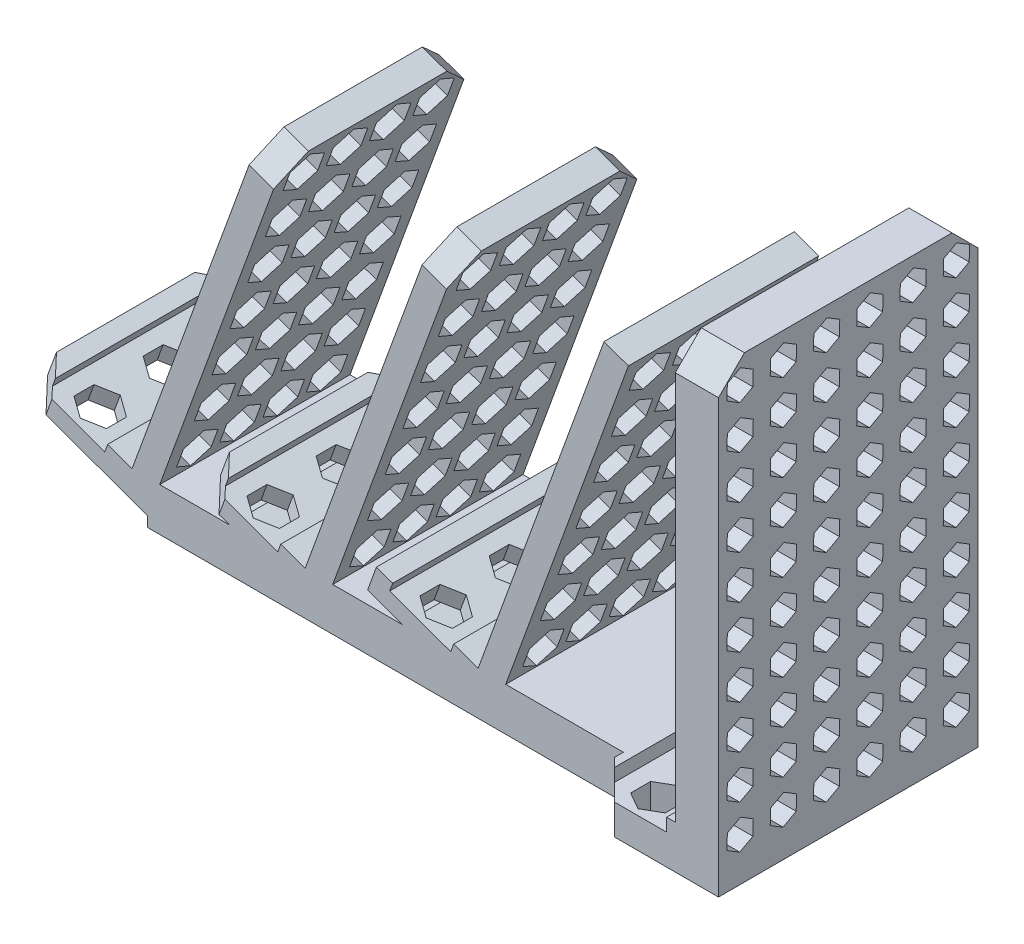
from build123d import *

# Parameters (mm, degrees)
SKETCH1_W           = 140
SKETCH1_H           = 44
BOSS_EXTRUDE1_DEPTH = 5
BOSS_EXTRUDE2_DEPTH = 22
LPATTERN1_COUNT     = 3
LPATTERN1_PITCH     = 40
SKETCH3_W           = 10
SKETCH3_H           = 60
BOSS_EXTRUDE3_DEPTH = 96
SKETCH4_W           = 60
SKETCH4_H           = 10
BOSS_EXTRUDE4_DEPTH = 30
CUT_EXTRUDE1_DEPTH  = 53
SKETCH6_W           = 16
SKETCH6_H           = 3
CUT_EXTRUDE2_DEPTH  = 61
CUT_EXTRUDE3_DEPTH  = 6
LPATTERN2_COUNT     = 3
LPATTERN2_PITCH     = 40
CUT_EXTRUDE7_DEPTH  = 10
CUT_EXTRUDE8_DEPTH  = 4
LPATTERN3_COUNT     = 3
LPATTERN3_PITCH     = 40
CUT_EXTRUDE9_DEPTH  = 7
CHAMFER1_SIZE       = 6


with BuildPart() as part:
    # Sketch1 → Boss-Extrude1 (new body, symmetric)
    with BuildSketch(Plane(origin=(0, 0, 0), x_dir=(1, 0, 0), z_dir=(0, 1, 0))):
        Rectangle(SKETCH1_W, SKETCH1_H)
    extrude(amount=BOSS_EXTRUDE1_DEPTH, both=True)

    # Sketch2 → Boss-Extrude2 (add, symmetric)
    with BuildSketch(Plane.XY):
        Polygon((-44.468416123, 85), (-73.586034865, 5), (-97.078350384, 13.550503583), (-99.130471244, 7.912347858), (-70, -2.690276585), (-38.830260399, 82.94787914), align=None)
    boss_extrude2 = extrude(amount=BOSS_EXTRUDE2_DEPTH, both=True)

    # LPattern1: Boss-Extrude2 ×3
    with Locations(*[(i * LPATTERN1_PITCH, 0, 0) for i in range(1, LPATTERN1_COUNT)]):
        add(boss_extrude2)

    # Sketch3 → Boss-Extrude3 (add)
    with BuildSketch(Plane(origin=(0, 5, 0), x_dir=(1, 0, 0), z_dir=(0, 1, 0))):
        with Locations((65, 0)):
            Rectangle(SKETCH3_W, SKETCH3_H)
    extrude(amount=BOSS_EXTRUDE3_DEPTH)

    # Sketch4 → Boss-Extrude4 (add)
    with BuildSketch(Plane(origin=(70, 0, 0), x_dir=(0, 0, -1), z_dir=(1, 0, 0))):
        Rectangle(SKETCH4_W, SKETCH4_H)
    extrude(amount=-BOSS_EXTRUDE4_DEPTH)

    # Sketch5 → Cut-Extrude1 (cut, through all)
    with BuildSketch(Plane.XY.offset(22)):
        Polygon((-93.319579901, 12.18242301), (-79.224190589, 7.05212086), (-79.908230876, 5.172735618), (-94.003620188, 10.303037768), align=None)
        Polygon((-39.908230876, 5.172735618), (-54.003620188, 10.303037768), (-53.319579901, 12.18242301), (-39.224190589, 7.05212086), align=None)
        Polygon((0.091769124, 5.172735618), (-14.003620188, 10.303037768), (-13.319579901, 12.18242301), (0.775809411, 7.05212086), align=None)
    extrude(amount=-CUT_EXTRUDE1_DEPTH, mode=Mode.SUBTRACT)

    # Sketch6 → Cut-Extrude2 (cut, through all)
    with BuildSketch(Plane.XY.offset(30)):
        with Locations((50, 3.5)):
            Rectangle(SKETCH6_W, SKETCH6_H)
    extrude(amount=-CUT_EXTRUDE2_DEPTH, mode=Mode.SUBTRACT)

    # Sketch7 → Cut-Extrude3 (cut)
    with BuildSketch(Plane(origin=(-66.585073006, 24.234984621, 0), x_dir=(0, 0, 1), z_dir=(-0.939692621, 0.342020143, 0))):
        Polygon((-15, 63.283580864), (-19, 60.974179788), (-19, 56.355377634), (-15, 54.045976557), (-11, 56.355377634), (-11, 60.974179788), align=None)
        Polygon((-15, 51.283580864), (-19, 48.974179788), (-19, 44.355377634), (-15, 42.045976557), (-11, 44.355377634), (-11, 48.974179788), align=None)
        Polygon((-15, 39.283580864), (-19, 36.974179788), (-19, 32.355377634), (-15, 30.045976557), (-11, 32.355377634), (-11, 36.974179788), align=None)
        Polygon((-15, 27.283580864), (-19, 24.974179788), (-19, 20.355377634), (-15, 18.045976557), (-11, 20.355377634), (-11, 24.974179788), align=None)
        Polygon((-15, 15.283580864), (-19, 12.974179788), (-19, 8.355377634), (-15, 6.045976557), (-11, 8.355377634), (-11, 12.974179788), align=None)
        Polygon((-15, 3.283580864), (-19, 0.974179788), (-19, -3.644622366), (-15, -5.954023443), (-11, -3.644622366), (-11, 0.974179788), align=None)
        Polygon((-15, -8.716419136), (-19, -11.025820212), (-19, -15.644622366), (-15, -17.954023443), (-11, -15.644622366), (-11, -11.025820212), align=None)
        Polygon((-5, 51.283580864), (-9, 48.974179788), (-9, 44.355377634), (-5, 42.045976557), (-1, 44.355377634), (-1, 48.974179788), align=None)
        Polygon((-5, 39.283580864), (-9, 36.974179788), (-9, 32.355377634), (-5, 30.045976557), (-1, 32.355377634), (-1, 36.974179788), align=None)
        Polygon((-5, 27.283580864), (-9, 24.974179788), (-9, 20.355377634), (-5, 18.045976557), (-1, 20.355377634), (-1, 24.974179788), align=None)
        Polygon((-5, 15.283580864), (-9, 12.974179788), (-9, 8.355377634), (-5, 6.045976557), (-1, 8.355377634), (-1, 12.974179788), align=None)
        Polygon((-5, 3.283580864), (-9, 0.974179788), (-9, -3.644622366), (-5, -5.954023443), (-1, -3.644622366), (-1, 0.974179788), align=None)
        Polygon((-5, -8.716419136), (-9, -11.025820212), (-9, -15.644622366), (-5, -17.954023443), (-1, -15.644622366), (-1, -11.025820212), align=None)
        Polygon((5, 51.283580864), (1, 48.974179788), (1, 44.355377634), (5, 42.045976557), (9, 44.355377634), (9, 48.974179788), align=None)
        Polygon((5, 39.283580864), (1, 36.974179788), (1, 32.355377634), (5, 30.045976557), (9, 32.355377634), (9, 36.974179788), align=None)
        Polygon((5, 27.283580864), (1, 24.974179788), (1, 20.355377634), (5, 18.045976557), (9, 20.355377634), (9, 24.974179788), align=None)
        Polygon((5, 15.283580864), (1, 12.974179788), (1, 8.355377634), (5, 6.045976557), (9, 8.355377634), (9, 12.974179788), align=None)
        Polygon((5, 3.283580864), (1, 0.974179788), (1, -3.644622366), (5, -5.954023443), (9, -3.644622366), (9, 0.974179788), align=None)
        Polygon((5, -8.716419136), (1, -11.025820212), (1, -15.644622366), (5, -17.954023443), (9, -15.644622366), (9, -11.025820212), align=None)
        Polygon((15, 51.283580864), (11, 48.974179788), (11, 44.355377634), (15, 42.045976557), (19, 44.355377634), (19, 48.974179788), align=None)
        Polygon((15, 39.283580864), (11, 36.974179788), (11, 32.355377634), (15, 30.045976557), (19, 32.355377634), (19, 36.974179788), align=None)
        Polygon((15, 27.283580864), (11, 24.974179788), (11, 20.355377634), (15, 18.045976557), (19, 20.355377634), (19, 24.974179788), align=None)
        Polygon((15, 15.283580864), (11, 12.974179788), (11, 8.355377634), (15, 6.045976557), (19, 8.355377634), (19, 12.974179788), align=None)
        Polygon((15, 3.283580864), (11, 0.974179788), (11, -3.644622366), (15, -5.954023443), (19, -3.644622366), (19, 0.974179788), align=None)
        Polygon((15, -8.716419136), (11, -11.025820212), (11, -15.644622366), (15, -17.954023443), (19, -15.644622366), (19, -11.025820212), align=None)
        Polygon((-5, 63.283580864), (-9, 60.974179788), (-9, 56.355377634), (-5, 54.045976557), (-1, 56.355377634), (-1, 60.974179788), align=None)
        Polygon((5, 63.283580864), (1, 60.974179788), (1, 56.355377634), (5, 54.045976557), (9, 56.355377634), (9, 60.974179788), align=None)
        Polygon((15, 63.283580864), (11, 60.974179788), (11, 56.355377634), (15, 54.045976557), (19, 56.355377634), (19, 60.974179788), align=None)
    cut_extrude3 = extrude(amount=-CUT_EXTRUDE3_DEPTH, mode=Mode.SUBTRACT)

    # LPattern2: Cut-Extrude3 ×3
    with Locations(*[(i * LPATTERN2_PITCH, 0, 0) for i in range(1, LPATTERN2_COUNT)]):
        add(cut_extrude3, mode=Mode.SUBTRACT)

    # Sketch12 → Cut-Extrude7 (cut)
    with BuildSketch(Plane(origin=(70, 0, 0), x_dir=(0, 0, -1), z_dir=(1, 0, 0))):
        Polygon((-22.040969404, 93.198850941), (-21.960643861, 96.662021138), (-24.919674457, 98.463170196), (-27.959030596, 96.801149059), (-28.039356139, 93.337978862), (-25.080325543, 91.536829804), align=None)
        Polygon((-24.919674457, 88.463170196), (-27.959030596, 86.801149059), (-28.039356139, 83.337978862), (-25.080325543, 81.536829804), (-22.040969404, 83.198850941), (-21.960643861, 86.662021138), align=None)
        Polygon((-24.919674457, 78.463170196), (-27.959030596, 76.801149059), (-28.039356139, 73.337978862), (-25.080325543, 71.536829804), (-22.040969404, 73.198850941), (-21.960643861, 76.662021138), align=None)
        Polygon((-24.919674457, 68.463170196), (-27.959030596, 66.801149059), (-28.039356139, 63.337978862), (-25.080325543, 61.536829804), (-22.040969404, 63.198850941), (-21.960643861, 66.662021138), align=None)
        Polygon((-24.919674457, 58.463170196), (-27.959030596, 56.801149059), (-28.039356139, 53.337978862), (-25.080325543, 51.536829804), (-22.040969404, 53.198850941), (-21.960643861, 56.662021138), align=None)
        Polygon((-24.919674457, 48.463170196), (-27.959030596, 46.801149059), (-28.039356139, 43.337978862), (-25.080325543, 41.536829804), (-22.040969404, 43.198850941), (-21.960643861, 46.662021138), align=None)
        Polygon((-24.919674457, 38.463170196), (-27.959030596, 36.801149059), (-28.039356139, 33.337978862), (-25.080325543, 31.536829804), (-22.040969404, 33.198850941), (-21.960643861, 36.662021138), align=None)
        Polygon((-24.919674457, 28.463170196), (-27.959030596, 26.801149059), (-28.039356139, 23.337978862), (-25.080325543, 21.536829804), (-22.040969404, 23.198850941), (-21.960643861, 26.662021138), align=None)
        Polygon((-24.919674457, 18.463170196), (-27.959030596, 16.801149059), (-28.039356139, 13.337978862), (-25.080325543, 11.536829804), (-22.040969404, 13.198850941), (-21.960643861, 16.662021138), align=None)
        Polygon((-24.919674457, 8.463170196), (-27.959030596, 6.801149059), (-28.039356139, 3.337978862), (-25.080325543, 1.536829804), (-22.040969404, 3.198850941), (-21.960643861, 6.662021138), align=None)
        Polygon((-14.919674457, 88.463170196), (-17.959030596, 86.801149059), (-18.039356139, 83.337978862), (-15.080325543, 81.536829804), (-12.040969404, 83.198850941), (-11.960643861, 86.662021138), align=None)
        Polygon((-14.919674457, 78.463170196), (-17.959030596, 76.801149059), (-18.039356139, 73.337978862), (-15.080325543, 71.536829804), (-12.040969404, 73.198850941), (-11.960643861, 76.662021138), align=None)
        Polygon((-14.919674457, 68.463170196), (-17.959030596, 66.801149059), (-18.039356139, 63.337978862), (-15.080325543, 61.536829804), (-12.040969404, 63.198850941), (-11.960643861, 66.662021138), align=None)
        Polygon((-14.919674457, 58.463170196), (-17.959030596, 56.801149059), (-18.039356139, 53.337978862), (-15.080325543, 51.536829804), (-12.040969404, 53.198850941), (-11.960643861, 56.662021138), align=None)
        Polygon((-14.919674457, 48.463170196), (-17.959030596, 46.801149059), (-18.039356139, 43.337978862), (-15.080325543, 41.536829804), (-12.040969404, 43.198850941), (-11.960643861, 46.662021138), align=None)
        Polygon((-14.919674457, 38.463170196), (-17.959030596, 36.801149059), (-18.039356139, 33.337978862), (-15.080325543, 31.536829804), (-12.040969404, 33.198850941), (-11.960643861, 36.662021138), align=None)
        Polygon((-14.919674457, 28.463170196), (-17.959030596, 26.801149059), (-18.039356139, 23.337978862), (-15.080325543, 21.536829804), (-12.040969404, 23.198850941), (-11.960643861, 26.662021138), align=None)
        Polygon((-14.919674457, 18.463170196), (-17.959030596, 16.801149059), (-18.039356139, 13.337978862), (-15.080325543, 11.536829804), (-12.040969404, 13.198850941), (-11.960643861, 16.662021138), align=None)
        Polygon((-14.919674457, 8.463170196), (-17.959030596, 6.801149059), (-18.039356139, 3.337978862), (-15.080325543, 1.536829804), (-12.040969404, 3.198850941), (-11.960643861, 6.662021138), align=None)
        Polygon((-4.919674457, 88.463170196), (-7.959030596, 86.801149059), (-8.039356139, 83.337978862), (-5.080325543, 81.536829804), (-2.040969404, 83.198850941), (-1.960643861, 86.662021138), align=None)
        Polygon((-4.919674457, 78.463170196), (-7.959030596, 76.801149059), (-8.039356139, 73.337978862), (-5.080325543, 71.536829804), (-2.040969404, 73.198850941), (-1.960643861, 76.662021138), align=None)
        Polygon((-4.919674457, 68.463170196), (-7.959030596, 66.801149059), (-8.039356139, 63.337978862), (-5.080325543, 61.536829804), (-2.040969404, 63.198850941), (-1.960643861, 66.662021138), align=None)
        Polygon((-4.919674457, 58.463170196), (-7.959030596, 56.801149059), (-8.039356139, 53.337978862), (-5.080325543, 51.536829804), (-2.040969404, 53.198850941), (-1.960643861, 56.662021138), align=None)
        Polygon((-4.919674457, 48.463170196), (-7.959030596, 46.801149059), (-8.039356139, 43.337978862), (-5.080325543, 41.536829804), (-2.040969404, 43.198850941), (-1.960643861, 46.662021138), align=None)
        Polygon((-4.919674457, 38.463170196), (-7.959030596, 36.801149059), (-8.039356139, 33.337978862), (-5.080325543, 31.536829804), (-2.040969404, 33.198850941), (-1.960643861, 36.662021138), align=None)
        Polygon((-4.919674457, 28.463170196), (-7.959030596, 26.801149059), (-8.039356139, 23.337978862), (-5.080325543, 21.536829804), (-2.040969404, 23.198850941), (-1.960643861, 26.662021138), align=None)
        Polygon((-4.919674457, 18.463170196), (-7.959030596, 16.801149059), (-8.039356139, 13.337978862), (-5.080325543, 11.536829804), (-2.040969404, 13.198850941), (-1.960643861, 16.662021138), align=None)
        Polygon((-4.919674457, 8.463170196), (-7.959030596, 6.801149059), (-8.039356139, 3.337978862), (-5.080325543, 1.536829804), (-2.040969404, 3.198850941), (-1.960643861, 6.662021138), align=None)
        Polygon((5.080325543, 88.463170196), (2.040969404, 86.801149059), (1.960643861, 83.337978862), (4.919674457, 81.536829804), (7.959030596, 83.198850941), (8.039356139, 86.662021138), align=None)
        Polygon((5.080325543, 78.463170196), (2.040969404, 76.801149059), (1.960643861, 73.337978862), (4.919674457, 71.536829804), (7.959030596, 73.198850941), (8.039356139, 76.662021138), align=None)
        Polygon((5.080325543, 68.463170196), (2.040969404, 66.801149059), (1.960643861, 63.337978862), (4.919674457, 61.536829804), (7.959030596, 63.198850941), (8.039356139, 66.662021138), align=None)
        Polygon((5.080325543, 58.463170196), (2.040969404, 56.801149059), (1.960643861, 53.337978862), (4.919674457, 51.536829804), (7.959030596, 53.198850941), (8.039356139, 56.662021138), align=None)
        Polygon((5.080325543, 48.463170196), (2.040969404, 46.801149059), (1.960643861, 43.337978862), (4.919674457, 41.536829804), (7.959030596, 43.198850941), (8.039356139, 46.662021138), align=None)
        Polygon((5.080325543, 38.463170196), (2.040969404, 36.801149059), (1.960643861, 33.337978862), (4.919674457, 31.536829804), (7.959030596, 33.198850941), (8.039356139, 36.662021138), align=None)
        Polygon((5.080325543, 28.463170196), (2.040969404, 26.801149059), (1.960643861, 23.337978862), (4.919674457, 21.536829804), (7.959030596, 23.198850941), (8.039356139, 26.662021138), align=None)
        Polygon((5.080325543, 18.463170196), (2.040969404, 16.801149059), (1.960643861, 13.337978862), (4.919674457, 11.536829804), (7.959030596, 13.198850941), (8.039356139, 16.662021138), align=None)
        Polygon((5.080325543, 8.463170196), (2.040969404, 6.801149059), (1.960643861, 3.337978862), (4.919674457, 1.536829804), (7.959030596, 3.198850941), (8.039356139, 6.662021138), align=None)
        Polygon((15.080325543, 88.463170196), (12.040969404, 86.801149059), (11.960643861, 83.337978862), (14.919674457, 81.536829804), (17.959030596, 83.198850941), (18.039356139, 86.662021138), align=None)
        Polygon((15.080325543, 78.463170196), (12.040969404, 76.801149059), (11.960643861, 73.337978862), (14.919674457, 71.536829804), (17.959030596, 73.198850941), (18.039356139, 76.662021138), align=None)
        Polygon((15.080325543, 68.463170196), (12.040969404, 66.801149059), (11.960643861, 63.337978862), (14.919674457, 61.536829804), (17.959030596, 63.198850941), (18.039356139, 66.662021138), align=None)
        Polygon((15.080325543, 58.463170196), (12.040969404, 56.801149059), (11.960643861, 53.337978862), (14.919674457, 51.536829804), (17.959030596, 53.198850941), (18.039356139, 56.662021138), align=None)
        Polygon((15.080325543, 48.463170196), (12.040969404, 46.801149059), (11.960643861, 43.337978862), (14.919674457, 41.536829804), (17.959030596, 43.198850941), (18.039356139, 46.662021138), align=None)
        Polygon((15.080325543, 38.463170196), (12.040969404, 36.801149059), (11.960643861, 33.337978862), (14.919674457, 31.536829804), (17.959030596, 33.198850941), (18.039356139, 36.662021138), align=None)
        Polygon((15.080325543, 28.463170196), (12.040969404, 26.801149059), (11.960643861, 23.337978862), (14.919674457, 21.536829804), (17.959030596, 23.198850941), (18.039356139, 26.662021138), align=None)
        Polygon((15.080325543, 18.463170196), (12.040969404, 16.801149059), (11.960643861, 13.337978862), (14.919674457, 11.536829804), (17.959030596, 13.198850941), (18.039356139, 16.662021138), align=None)
        Polygon((15.080325543, 8.463170196), (12.040969404, 6.801149059), (11.960643861, 3.337978862), (14.919674457, 1.536829804), (17.959030596, 3.198850941), (18.039356139, 6.662021138), align=None)
        Polygon((25.080325543, 88.463170196), (22.040969404, 86.801149059), (21.960643861, 83.337978862), (24.919674457, 81.536829804), (27.959030596, 83.198850941), (28.039356139, 86.662021138), align=None)
        Polygon((25.080325543, 78.463170196), (22.040969404, 76.801149059), (21.960643861, 73.337978862), (24.919674457, 71.536829804), (27.959030596, 73.198850941), (28.039356139, 76.662021138), align=None)
        Polygon((25.080325543, 68.463170196), (22.040969404, 66.801149059), (21.960643861, 63.337978862), (24.919674457, 61.536829804), (27.959030596, 63.198850941), (28.039356139, 66.662021138), align=None)
        Polygon((25.080325543, 58.463170196), (22.040969404, 56.801149059), (21.960643861, 53.337978862), (24.919674457, 51.536829804), (27.959030596, 53.198850941), (28.039356139, 56.662021138), align=None)
        Polygon((25.080325543, 48.463170196), (22.040969404, 46.801149059), (21.960643861, 43.337978862), (24.919674457, 41.536829804), (27.959030596, 43.198850941), (28.039356139, 46.662021138), align=None)
        Polygon((25.080325543, 38.463170196), (22.040969404, 36.801149059), (21.960643861, 33.337978862), (24.919674457, 31.536829804), (27.959030596, 33.198850941), (28.039356139, 36.662021138), align=None)
        Polygon((25.080325543, 28.463170196), (22.040969404, 26.801149059), (21.960643861, 23.337978862), (24.919674457, 21.536829804), (27.959030596, 23.198850941), (28.039356139, 26.662021138), align=None)
        Polygon((25.080325543, 18.463170196), (22.040969404, 16.801149059), (21.960643861, 13.337978862), (24.919674457, 11.536829804), (27.959030596, 13.198850941), (28.039356139, 16.662021138), align=None)
        Polygon((25.080325543, 8.463170196), (22.040969404, 6.801149059), (21.960643861, 3.337978862), (24.919674457, 1.536829804), (27.959030596, 3.198850941), (28.039356139, 6.662021138), align=None)
        Polygon((-14.919674457, 98.463170196), (-17.959030596, 96.801149059), (-18.039356139, 93.337978862), (-15.080325543, 91.536829804), (-12.040969404, 93.198850941), (-11.960643861, 96.662021138), align=None)
        Polygon((-4.919674457, 98.463170196), (-7.959030596, 96.801149059), (-8.039356139, 93.337978862), (-5.080325543, 91.536829804), (-2.040969404, 93.198850941), (-1.960643861, 96.662021138), align=None)
        Polygon((5.080325543, 98.463170196), (2.040969404, 96.801149059), (1.960643861, 93.337978862), (4.919674457, 91.536829804), (7.959030596, 93.198850941), (8.039356139, 96.662021138), align=None)
        Polygon((15.080325543, 98.463170196), (12.040969404, 96.801149059), (11.960643861, 93.337978862), (14.919674457, 91.536829804), (17.959030596, 93.198850941), (18.039356139, 96.662021138), align=None)
        Polygon((25.080325543, 98.463170196), (22.040969404, 96.801149059), (21.960643861, 93.337978862), (24.919674457, 91.536829804), (27.959030596, 93.198850941), (28.039356139, 96.662021138), align=None)
    extrude(amount=-CUT_EXTRUDE7_DEPTH, mode=Mode.SUBTRACT)

    # Sketch13 → Cut-Extrude8 (cut)
    with BuildSketch(Plane(origin=(-7.685002145, -21.114369862, 0), x_dir=(0.939692621, -0.342020143, 0), z_dir=(0.342020143, 0.939692621, 0))):
        Polygon((-80.364814818, 13.679445591), (-80.351925676, 18.29822976), (-84.34546553, 20.618784169), (-88.351894526, 18.320554409), (-88.364783668, 13.70177024), (-84.371243814, 11.381215831), align=None)
        Polygon((-80.358354672, -2.309401077), (-80.358354672, 2.309401077), (-84.358354672, 4.618802154), (-88.358354672, 2.309401077), (-88.358354672, -2.309401077), (-84.358354672, -4.618802154), align=None)
        Polygon((-80.364814818, -18.320554409), (-80.351925676, -13.70177024), (-84.34546553, -11.381215831), (-88.351894526, -13.679445591), (-88.364783668, -18.29822976), (-84.371243814, -20.618784169), align=None)
    cut_extrude8 = extrude(amount=-CUT_EXTRUDE8_DEPTH, mode=Mode.SUBTRACT)

    # LPattern3: Cut-Extrude8 ×3
    with Locations(*[(i * LPATTERN3_PITCH, 0, 0) for i in range(1, LPATTERN3_COUNT)]):
        add(cut_extrude8, mode=Mode.SUBTRACT)

    # Sketch14 → Cut-Extrude9 (cut)
    with BuildSketch(Plane(origin=(0, 2, 0), x_dir=(1, 0, 0), z_dir=(0, 1, 0))):
        Polygon((54, -9.690598923), (50, -7.381197846), (46, -9.690598923), (46, -14.309401077), (50, -16.618802154), (54, -14.309401077), align=None)
        Polygon((54, -26.309401077), (54, -21.690598923), (50, -19.381197846), (46, -21.690598923), (46, -26.309401077), (50, -28.618802154), align=None)
        Polygon((54, 2.309401077), (50, 4.618802154), (46, 2.309401077), (46, -2.309401077), (50, -4.618802154), (54, -2.309401077), align=None)
        Polygon((54, 14.309401077), (50, 16.618802154), (46, 14.309401077), (46, 9.690598923), (50, 7.381197846), (54, 9.690598923), align=None)
        Polygon((54, 26.309401077), (50, 28.618802154), (46, 26.309401077), (46, 21.690598923), (50, 19.381197846), (54, 21.690598923), align=None)
    extrude(amount=-CUT_EXTRUDE9_DEPTH, mode=Mode.SUBTRACT)

    # Chamfer1
    chamfer1_edges = [part.edges().sort_by_distance(p)[0] for p in [
        (-98.104410814, 10.731425721, -22),
        (-98.104410814, 10.731425721, 22),
        (-41.649338261, 83.97393957, -22),
        (-41.649338261, 83.97393957, 22),
        (-1.649338261, 83.97393957, -22),
        (-1.649338261, 83.97393957, 22),
        (65, 101, -30),
        (65, 101, 30),
        (40, 0, -30),
        (40, 0, 30),
        (-58.104410814, 10.731425721, -22),
        (-58.104410814, 10.731425721, 22),
    ]]
    chamfer(chamfer1_edges, length=CHAMFER1_SIZE)


solid = part.part
